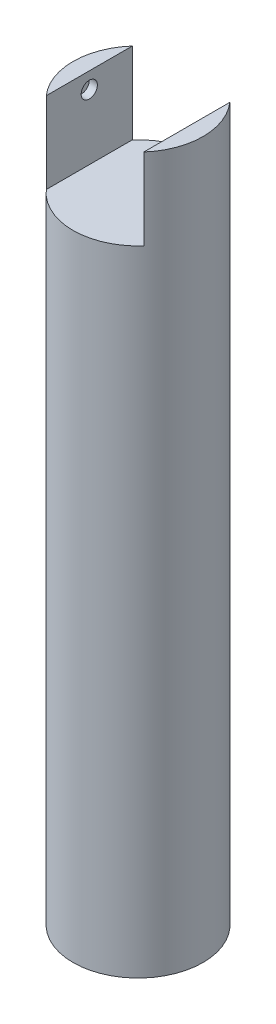
from build123d import *

# Parameters (mm, degrees)
SKETCH2_R           = 20
BOSS_EXTRUDE1_DEPTH = 220
SKETCH3_W           = 30
SKETCH3_H           = 41.781255482
CUT_EXTRUDE1_DEPTH  = 25
SKETCH4_R           = 2.5
CUT_EXTRUDE2_DEPTH  = 2.5


with BuildPart() as part:
    # Sketch2 → Boss-Extrude1 (new body)
    with BuildSketch(Plane(origin=(0, 0, 0), x_dir=(1, 0, 0), z_dir=(0, 1, 0))):
        Circle(SKETCH2_R)
    extrude(amount=BOSS_EXTRUDE1_DEPTH)

    # Sketch3 → Cut-Extrude1 (cut)
    with BuildSketch(Plane(origin=(0, 220, 0), x_dir=(1, 0, 0), z_dir=(0, 1, 0))):
        Rectangle(SKETCH3_W, SKETCH3_H)
    extrude(amount=-CUT_EXTRUDE1_DEPTH, mode=Mode.SUBTRACT)

    # Sketch4 → Cut-Extrude2 (cut)
    with BuildSketch(Plane(origin=(-15, 0, 0), x_dir=(0, 0, -1), z_dir=(1, 0, 0))):
        with Locations((0, 215)):
            Circle(SKETCH4_R)
    cut_extrude2 = extrude(amount=-CUT_EXTRUDE2_DEPTH, mode=Mode.SUBTRACT)

    # Mirror1: Cut-Extrude2 across plane
    add(cut_extrude2.mirror(Plane(origin=(0, 0, 0), x_dir=(0, 0, 1), z_dir=(1, 0, 0))), mode=Mode.SUBTRACT)


solid = part.part
